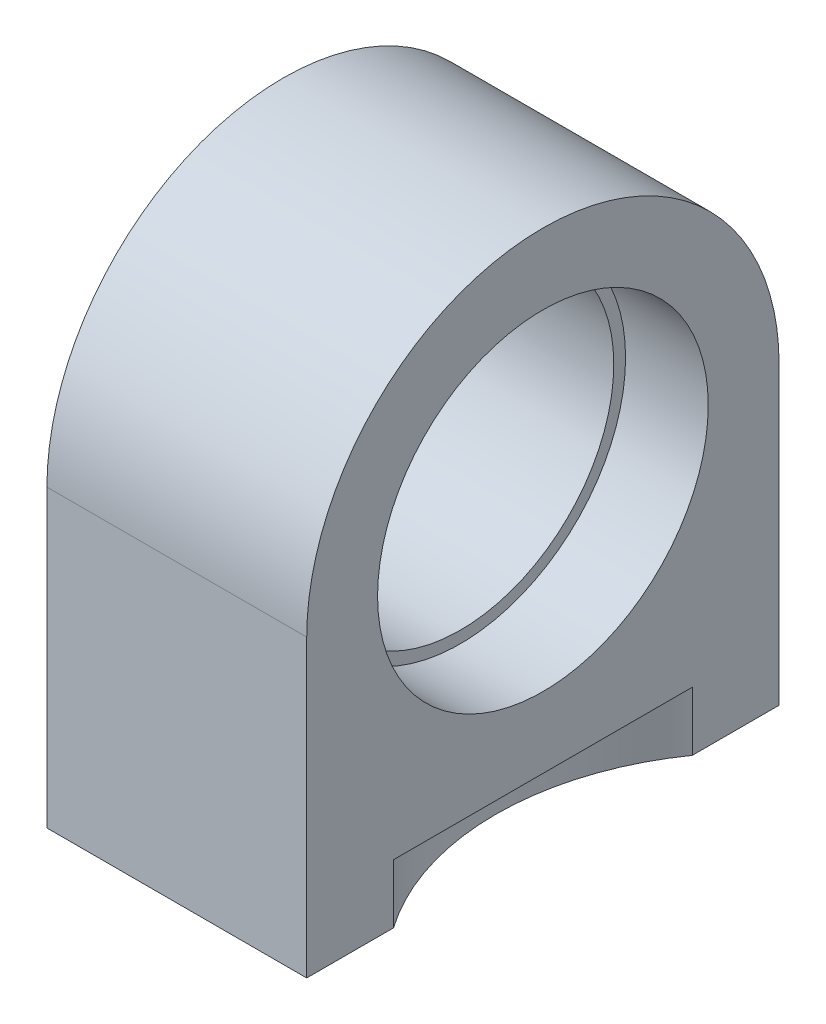
from build123d import *

# Parameters (mm, degrees)
SKIZZE1_R                       = 6.5
AUFSATZ_LINEAR_AUSTRAGEN1_DEPTH = 11
SKIZZE2_R                       = 7
SCHNITT_LINEAR_AUSTRAGEN1_DEPTH = 3.5
SKIZZE3_R                       = 2.75
SCHNITT_LINEAR_AUSTRAGEN2_DEPTH = 6
SKIZZE4_R                       = 11
SCHNITT_LINEAR_AUSTRAGEN3_DEPTH = 2.5


with BuildPart() as part:
    # Skizze1 → Aufsatz-Linear austragen1 (new body)
    with BuildSketch(Plane(origin=(0, 0, 0), x_dir=(0, 0, -1), z_dir=(1, 0, 0))):
        with BuildLine():
            Line((-10, 0), (-10, -12.5))
            Line((-10, -12.5), (10, -12.5))
            Line((10, -12.5), (10, 0))
            ThreePointArc((10, 0), (0, 10), (-10, 0))
        make_face()
        Circle(SKIZZE1_R, mode=Mode.SUBTRACT)
    extrude(amount=AUFSATZ_LINEAR_AUSTRAGEN1_DEPTH)

    # Skizze2 → Schnitt-Linear austragen1 (cut)
    with BuildSketch(Plane(origin=(11, 0, 0), x_dir=(0, 0, -1), z_dir=(1, 0, 0))):
        Circle(SKIZZE2_R)
    extrude(amount=-SCHNITT_LINEAR_AUSTRAGEN1_DEPTH, mode=Mode.SUBTRACT)

    # Skizze3 → Schnitt-Linear austragen2 (cut)
    with BuildSketch(Plane.XZ.offset(12.5)):
        with Locations((6, 5)):
            Circle(SKIZZE3_R)
        with Locations((6, -5)):
            Circle(SKIZZE3_R)
    extrude(amount=-SCHNITT_LINEAR_AUSTRAGEN2_DEPTH, mode=Mode.SUBTRACT)

    # Skizze4 → Schnitt-Linear austragen3 (cut)
    with BuildSketch(Plane.XZ.offset(12.5)):
        with Locations((20, 0)):
            Circle(SKIZZE4_R)
    extrude(amount=-SCHNITT_LINEAR_AUSTRAGEN3_DEPTH, mode=Mode.SUBTRACT)


solid = part.part
